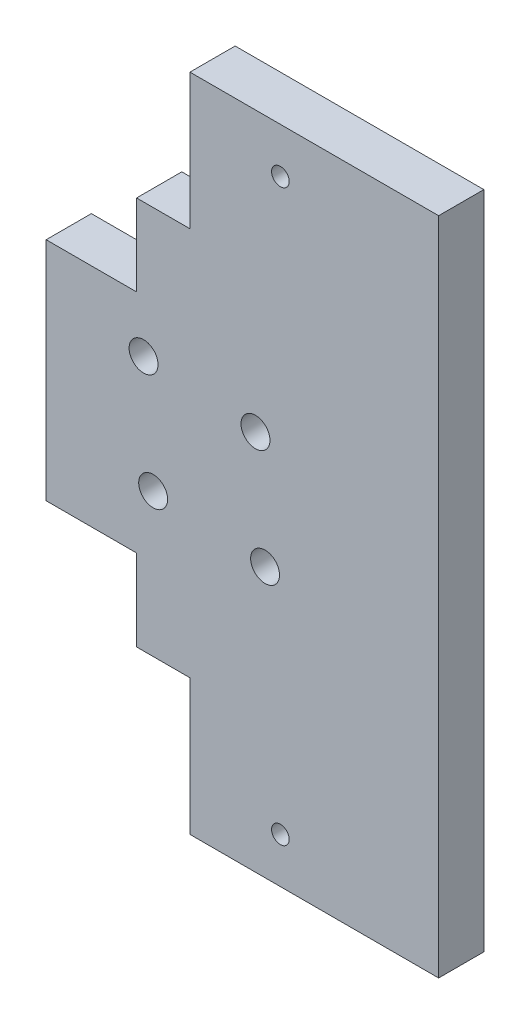
from build123d import *

# Parameters (mm, degrees)
SKETCH1_W           = 38.4
SKETCH1_H           = 73
BOSS_EXTRUDE1_DEPTH = 5
SKETCH4_W           = 5
SKETCH4_H           = 25
BOSS_EXTRUDE3_DEPTH = 10
SKETCH5_R           = 1.6
CUT_EXTRUDE1_DEPTH  = 25
SKETCH6_W           = 5
SKETCH6_H           = 15
CUT_EXTRUDE2_DEPTH  = 5.9
SKETCH8_W           = 5
SKETCH8_H           = 73
CUT_EXTRUDE3_DEPTH  = 10
SKETCH9_R           = 0.975
CUT_EXTRUDE4_DEPTH  = 13


with BuildPart() as part:
    # Sketch1 → Boss-Extrude1 (new body)
    with BuildSketch(Plane.XY):
        Rectangle(SKETCH1_W, SKETCH1_H)
    extrude(amount=BOSS_EXTRUDE1_DEPTH)

    # Sketch4 → Boss-Extrude3 (add)
    with BuildSketch(Plane.ZY.offset(19.2)):
        with Locations((2.5, 0)):
            Rectangle(SKETCH4_W, SKETCH4_H)
    extrude(amount=BOSS_EXTRUDE3_DEPTH)

    # Sketch5 → Cut-Extrude1 (cut)
    with BuildSketch(Plane.XY.offset(5)):
        with Locations((-18.427514421, 6.717514421)):
            Circle(SKETCH5_R)
        with Locations((-6.053145751, 5.656854249)):
            Circle(SKETCH5_R)
        with Locations((-17.366854249, -5.656854249)):
            Circle(SKETCH5_R)
        with Locations((-4.992485579, -6.717514421)):
            Circle(SKETCH5_R)
    extrude(amount=-CUT_EXTRUDE1_DEPTH, mode=Mode.SUBTRACT)

    # Sketch6 → Cut-Extrude2 (cut)
    with BuildSketch(Plane.ZY.offset(19.2)):
        with Locations((2.5, 29)):
            Rectangle(SKETCH6_W, SKETCH6_H)
        with Locations((2.5, -29)):
            Rectangle(SKETCH6_W, SKETCH6_H)
    extrude(amount=-CUT_EXTRUDE2_DEPTH, mode=Mode.SUBTRACT)

    # Sketch8 → Cut-Extrude3 (cut)
    with BuildSketch(Plane(origin=(0, 0, 0), x_dir=(-1, 0, 0), z_dir=(0, 0, -1))):
        with Locations((-16.7, 0)):
            Rectangle(SKETCH8_W, SKETCH8_H)
    extrude(amount=-CUT_EXTRUDE3_DEPTH, mode=Mode.SUBTRACT)

    # Sketch9 → Cut-Extrude4 (cut)
    with BuildSketch(Plane(origin=(0, 0, 0), x_dir=(-1, 0, 0), z_dir=(0, 0, -1))):
        with Locations((3.3, 31.5)):
            Circle(SKETCH9_R)
        with Locations((3.3, -31.5)):
            Circle(SKETCH9_R)
    extrude(amount=-CUT_EXTRUDE4_DEPTH, mode=Mode.SUBTRACT)


solid = part.part
